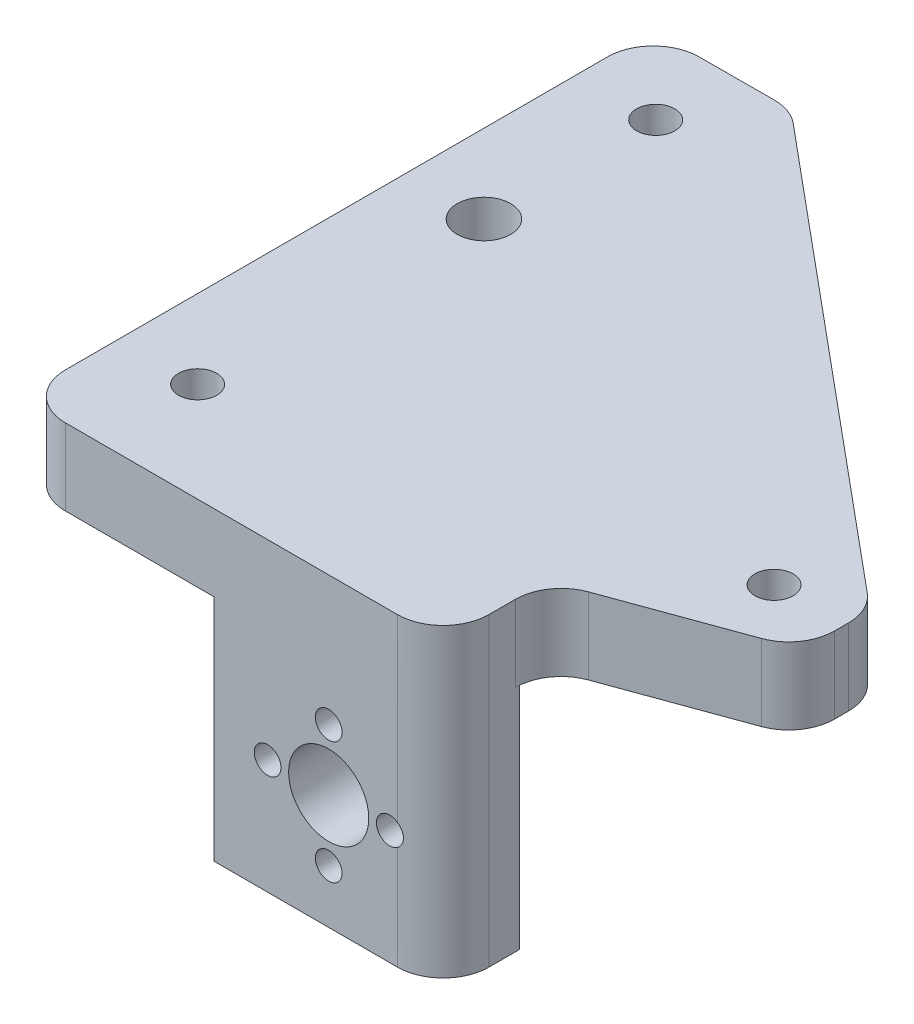
from build123d import *

# Parameters (mm, degrees)
SKETCH1_R           = 2.5
SKETCH1_R_2         = 3.5
BOSS_EXTRUDE2_DEPTH = 10
BOSS_EXTRUDE4_DEPTH = 30
SKETCH6_R           = 1.75
SKETCH6_R_2         = 5.25
CUT_EXTRUDE1_DEPTH  = 11


with BuildPart() as part:
    # Sketch1 → Boss-Extrude2 (new body)
    with BuildSketch(Plane(origin=(0, 0, 0), x_dir=(1, 0, 0), z_dir=(0, 1, 0))):
        with BuildLine():
            Line((0, 77.021298835), (0, 6))
            ThreePointArc((0, 6), (1.757359313, 1.757359313), (6, 0))
            Line((6, 0), (25.5, 0))
            Line((25.5, 0), (49.5, 0))
            ThreePointArc((49.5, 0), (53.742640687, 1.757359313), (55.5, 6))
            Line((55.5, 6), (55.5, 9.44767998))
            ThreePointArc((55.5, 9.44767998), (56.585087734, 12.889138599), (59.44787914, 15.085835705))
            Line((59.44787914, 15.085835705), (76.05212086, 21.129285454))
            ThreePointArc((76.05212086, 21.129285454), (78.914912266, 23.32598256), (80, 26.767441178))
            Line((80, 26.767441178), (80, 28.603492695))
            ThreePointArc((80, 28.603492695), (79.433329493, 31.148867053), (77.840356459, 33.213445219))
            Line((77.840356459, 33.213445219), (19.677771687, 81.666234475))
            ThreePointArc((19.677771687, 81.666234475), (17.86947323, 82.701699586), (15.816078589, 83.056244014))
            Line((15.816078589, 83.056244014), (5.978663362, 83.021260897))
            ThreePointArc((5.978663362, 83.021260897), (1.749822367, 81.256389163), (0, 77.021298835))
        make_face()
        with Locations((10.3, 13.036564897)):
            Circle(SKETCH1_R, mode=Mode.SUBTRACT)
        with Locations((70.8, 28.036564897)):
            Circle(SKETCH1_R, mode=Mode.SUBTRACT)
        with Locations((10.3, 50.536564897)):
            Circle(SKETCH1_R_2, mode=Mode.SUBTRACT)
        with Locations((10.3, 73.036564897)):
            Circle(SKETCH1_R, mode=Mode.SUBTRACT)
    extrude(amount=BOSS_EXTRUDE2_DEPTH)

    # Sketch5 → Boss-Extrude4 (add)
    with BuildSketch(Plane(origin=(0, 0, 0), x_dir=(1, 0, 0), z_dir=(0, 1, 0))):
        with BuildLine():
            Line((55.5, 6), (55.5, 10))
            Line((55.5, 10), (25.5, 10))
            Line((25.5, 10), (25.5, 0))
            Line((25.5, 0), (49.5, 0))
            ThreePointArc((49.5, 0), (53.742640687, 1.757359313), (55.5, 6))
        make_face()
    extrude(amount=-BOSS_EXTRUDE4_DEPTH)

    # Sketch6 → Cut-Extrude1 (cut, through all)
    with BuildSketch(Plane(origin=(0, 0, -10), x_dir=(-1, 0, 0), z_dir=(0, 0, -1))):
        with Locations((-40.5, -7)):
            Circle(SKETCH6_R)
        with Locations((-40.5, -23)):
            Circle(SKETCH6_R)
        with Locations((-48.5, -15)):
            Circle(SKETCH6_R)
        with Locations((-32.5, -15)):
            Circle(SKETCH6_R)
        with Locations((-40.5, -15)):
            Circle(SKETCH6_R_2)
    extrude(amount=-CUT_EXTRUDE1_DEPTH, mode=Mode.SUBTRACT)


solid = part.part
